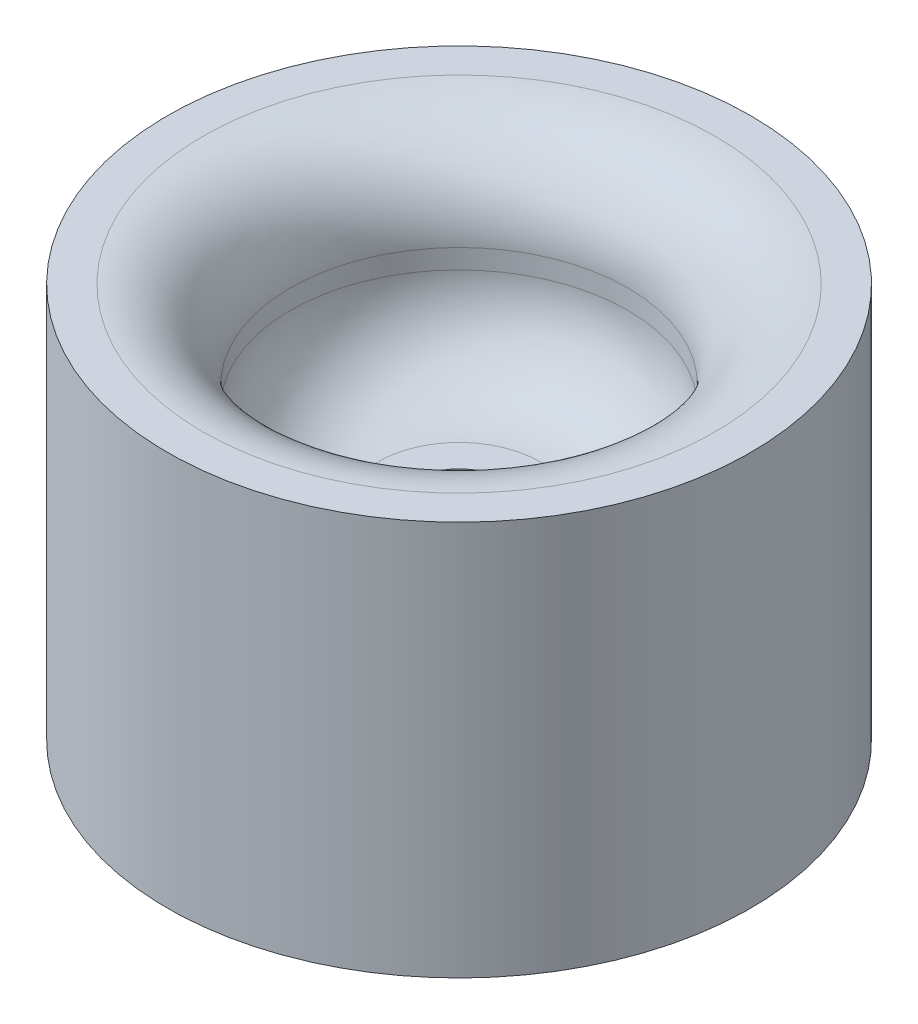
from build123d import *

# Parameters (mm, degrees)
SKETCH2_R          = 12.7
CUT_EXTRUDE1_DEPTH = 77.2
SKETCH3_R          = 76.2
CUT_EXTRUDE2_DEPTH = 23.876


with BuildPart() as part:
    # Sketch1 → Revolve1 (revolve)
    with BuildSketch(Plane(origin=(0, 0, 0), x_dir=(0, 0, -1), z_dir=(1, 0, 0))):
        with BuildLine():
            Line((0, 0), (0, 76.2))
            Line((0, 76.2), (-21.180812514, 76.2))
            ThreePointArc((-21.180812514, 76.2), (-37.345273532, 82.895538982), (-44.040812514, 99.06))
            Line((-44.040812514, 99.06), (-44.040812514, 104.14))
            ThreePointArc((-44.040812514, 104.14), (-50.736351496, 120.304461018), (-66.900812514, 127))
            Line((-66.900812514, 127), (-76.2, 127))
            Line((-76.2, 127), (-76.2, 0))
            Line((-76.2, 0), (0, 0))
        make_face()
    revolve(axis=Axis((0, 0, 0), (0, 1, 0)))

    # Sketch2 → Cut-Extrude1 (cut, through all)
    with BuildSketch(Plane(origin=(0, 76.2, 0), x_dir=(1, 0, 0), z_dir=(0, 1, 0))):
        Circle(SKETCH2_R)
    extrude(amount=-CUT_EXTRUDE1_DEPTH, mode=Mode.SUBTRACT)

    # Sketch3 → Cut-Extrude2 (cut)
    with BuildSketch(Plane(origin=(0, 0, 0), x_dir=(-1, 0, 0), z_dir=(0, -1, 0))):
        Circle(SKETCH3_R)
    extrude(amount=-CUT_EXTRUDE2_DEPTH, mode=Mode.SUBTRACT)


solid = part.part
